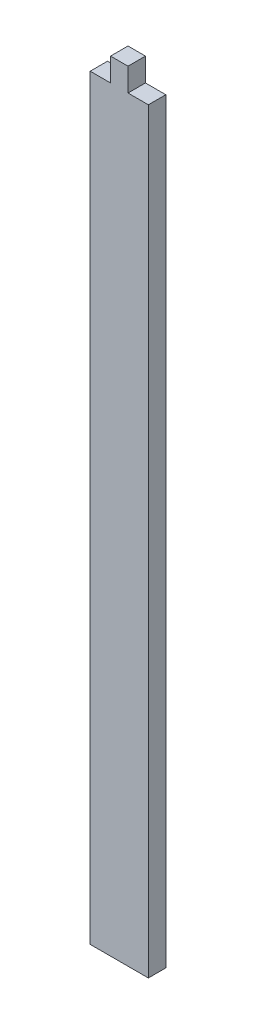
from build123d import *

# Parameters (mm, degrees)
BOSS_EXTRUDE1_DEPTH = 1.5


with BuildPart() as part:
    # Sketch1 → Boss-Extrude1 (new body, symmetric)
    with BuildSketch(Plane.XY):
        Polygon((1.5, 65), (5, 65), (5, -65), (-5, -65), (-5, 65), (-1.5, 65), (-1.5, 69), (1.5, 69), align=None)
    extrude(amount=BOSS_EXTRUDE1_DEPTH, both=True)


solid = part.part
